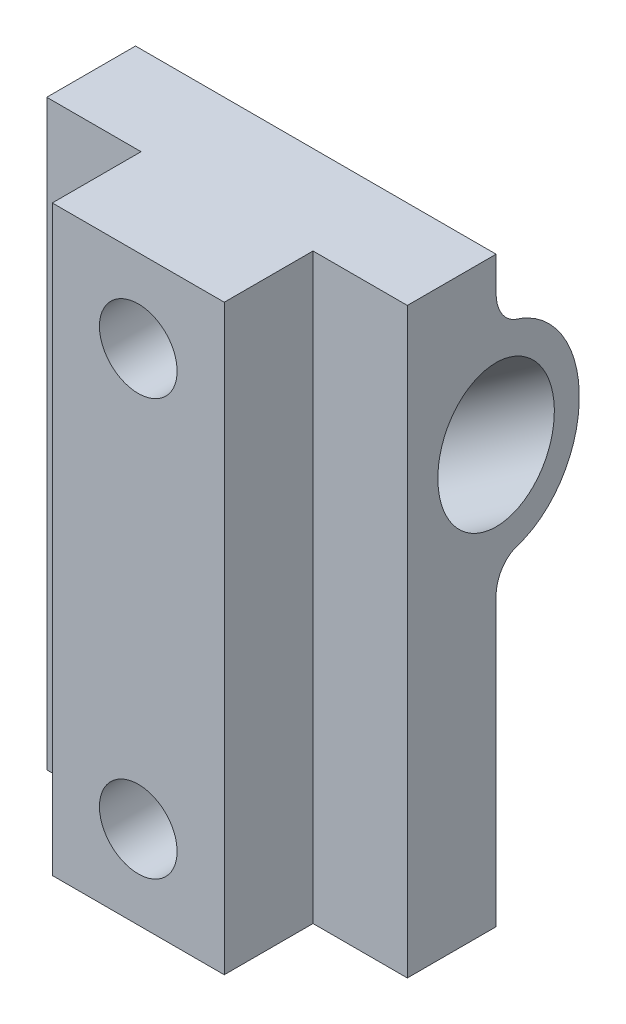
from build123d import *

# Parameters (mm, degrees)
BOSS_EXTRUDE1_DEPTH             = 105
SKETCH2_R                       = 7
CUT_EXTRUDE1_DEPTH              = 105
BOSS_EXTRUDE2_REACH             = 109.369
SKETCH8_R                       = 15
SKETCH8_R_2                     = 10.5
BOSS_EXTRUDE2_DIRECTION_2_REACH = 109.369
CUT_EXTRUDE2_DEPTH              = 108.368909468
CUT_EXTRUDE2_DEPTH_BACK         = 108.368909468
SKETCH8_2_R                     = 10.5
FILLET2_R                       = 5


with BuildPart() as part:
    # Sketch1 → Boss-Extrude1 (new body)
    with BuildSketch(Plane(origin=(0, 0, 0), x_dir=(1, 0, 0), z_dir=(0, 1, 0))):
        Polygon((-32.5, 8), (-32.5, -8), (-15.5, -8), (-15.5, -24), (15.5, -24), (15.5, -8), (32.5, -8), (32.5, 8), align=None)
    extrude(amount=BOSS_EXTRUDE1_DEPTH)

    # Sketch2 → Cut-Extrude1 (cut)
    with BuildSketch(Plane(origin=(0, 0, -8), x_dir=(-1, 0, 0), z_dir=(0, 0, -1))):
        with Locations((0, 90)):
            Circle(SKETCH2_R)
        with Locations((0, 15)):
            Circle(SKETCH2_R)
    extrude(amount=-CUT_EXTRUDE1_DEPTH, mode=Mode.SUBTRACT)

    # Boss-Extrude2: up to this plane
    boss_extrude2_end = Plane(origin=(-32.5, 105, 0), z_dir=(1, 0, 0))
    # Sketch8 → Boss-Extrude2 (add, up to the surface)
    with BuildSketch(Plane(origin=(27.526035262, 19.273937388, 0), x_dir=(0, 0, 1), z_dir=(-0.819152044288991, -0.5735764363510473, 0)), mode=Mode.PRIVATE) as boss_extrude2_sk1:
        with Locations((-8, 43.005482325)):
            Circle(SKETCH8_R)
        with Locations((-8, 43.005482325)):
            Circle(SKETCH8_R_2, mode=Mode.SUBTRACT)
    boss_extrude2_tool1 = split(extrude(boss_extrude2_sk1.sketch, amount=BOSS_EXTRUDE2_REACH, mode=Mode.PRIVATE), bisect_by=boss_extrude2_end, keep=Keep.BOTH, mode=Mode.PRIVATE)
    add(boss_extrude2_tool1.solids().sort_by_distance((2.859104, 54.501966, -22.575736))[0])

    # Boss-Extrude2 direction 2: up to this plane
    boss_extrude2_direction_2_end = Plane(origin=(32.5, 105, 0), z_dir=(1, 0, 0))
    # Sketch8 → Boss-Extrude2 direction 2 (add, up to the surface)
    with BuildSketch(Plane(origin=(27.526035262, 19.273937388, 0), x_dir=(0, 0, 1), z_dir=(-0.819152044288991, -0.5735764363510473, 0)), mode=Mode.PRIVATE) as boss_extrude2_direction_2_sk1:
        with Locations((-8, 43.005482325)):
            Circle(SKETCH8_R)
        with Locations((-8, 43.005482325)):
            Circle(SKETCH8_R_2, mode=Mode.SUBTRACT)
    boss_extrude2_direction_2_tool1 = split(extrude(boss_extrude2_direction_2_sk1.sketch, amount=-BOSS_EXTRUDE2_DIRECTION_2_REACH, mode=Mode.PRIVATE), bisect_by=boss_extrude2_direction_2_end, keep=Keep.BOTH, mode=Mode.PRIVATE)
    add(boss_extrude2_direction_2_tool1.solids().sort_by_distance((2.859104, 54.501966, -22.575736))[0])

    # Sketch8_2 → Cut-Extrude2 (cut, two sides: drawn at the far end of the back side and taken through both)
    with BuildSketch(Plane(origin=(27.526035262, 19.273937388, 0), x_dir=(0, 0, 1), z_dir=(-0.819152044288991, -0.5735764363510473, 0)).offset(-CUT_EXTRUDE2_DEPTH_BACK)):
        with Locations((-8, 43.005482325)):
            Circle(SKETCH8_2_R)
    extrude(amount=CUT_EXTRUDE2_DEPTH + CUT_EXTRUDE2_DEPTH_BACK, mode=Mode.SUBTRACT)

    # Fillet2
    fillet2_edges = [part.edges().sort_by_distance(p)[0] for p in [
        (0, 70.811618831, -8),
        (0, 34.188381169, -8),
    ]]
    fillet(fillet2_edges, radius=FILLET2_R)


solid = part.part
